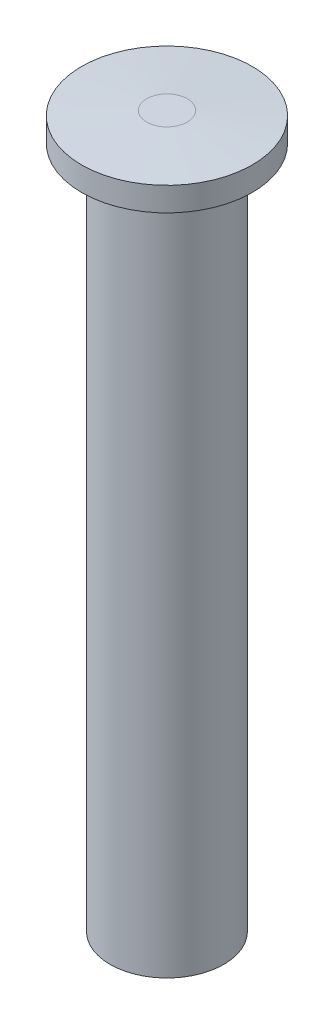
from build123d import *

# Parameters (mm, degrees)
SKETCH1_R           = 3.175
BOSS_EXTRUDE1_DEPTH = 19.05
SKETCH2_R           = 4.7625
BOSS_EXTRUDE2_DEPTH = 1.5875
CHAMFER1_SIZE       = 0.254
CHAMFER1_SIZE2      = 3.632369229


with BuildPart() as part:
    # Sketch1 → Boss-Extrude1 (new body, symmetric)
    with BuildSketch(Plane(origin=(0, 0, 0), x_dir=(1, 0, 0), z_dir=(0, 1, 0))):
        Circle(SKETCH1_R)
    extrude(amount=BOSS_EXTRUDE1_DEPTH, both=True)

    # Sketch2 → Boss-Extrude2 (add)
    with BuildSketch(Plane(origin=(0, 19.05, 0), x_dir=(1, 0, 0), z_dir=(0, 1, 0))):
        Circle(SKETCH2_R)
    extrude(amount=BOSS_EXTRUDE2_DEPTH)

    # Chamfer1
    chamfer1_edges = [part.edges().sort_by_distance(p)[0] for p in [
        (-4.7625, 20.6375, 0),
    ]]
    chamfer1_side = [part.faces().sort_by_distance(p)[0] for p in [
        (-4.7625, 19.84375, 0),
    ]]
    chamfer(chamfer1_edges, length=CHAMFER1_SIZE, length2=CHAMFER1_SIZE2, reference=chamfer1_side[0])


solid = part.part
